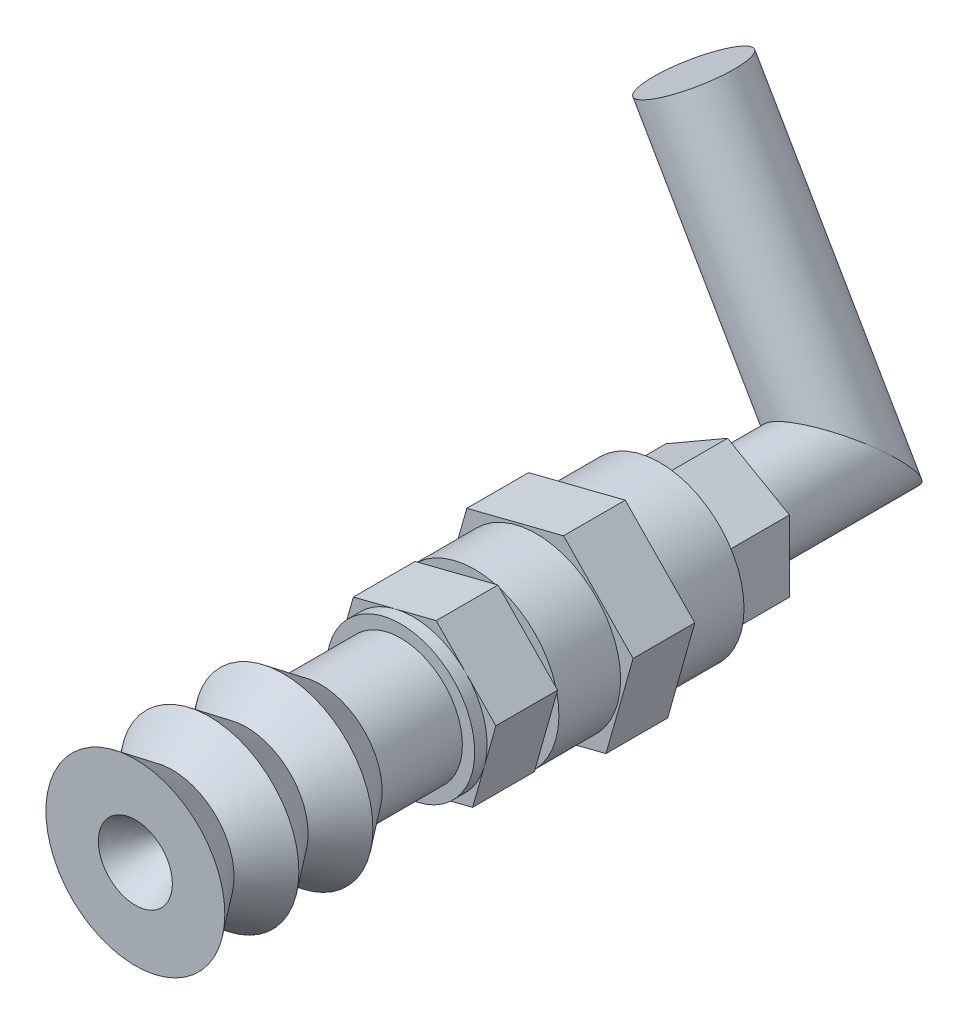
from build123d import *

# Parameters (mm, degrees)
ESQUISSE1_R             = 6.825
BOSS_EXTRU_1_DEPTH      = 5
BOSS_EXTRU_2_DEPTH      = 5
ESQUISSE3_R             = 6.825
BOSS_EXTRU_3_DEPTH      = 5
BOSS_EXTRU_4_DEPTH      = 5
ESQUISSE5_R             = 6
BOSS_EXTRU_5_DEPTH      = 1
ESQUISSE8_R             = 4
BOSS_EXTRU_6_DEPTH      = 4
BOSS_EXTRU_7_DEPTH      = 5.5
ESQUISSE11_R            = 3.75
BOSS_EXTRU_8_DEPTH      = 13
ESQUISSE15_R            = 3.75
BOSS_EXTRU_9_DEPTH      = 19
BOSS_EXTRU_9_DEPTH_BACK = 11
ENL_V_MAT_EXTRU_1_DEPTH = 36
ENL_V_MAT_EXTRU_2_DEPTH = 24


with BuildPart() as part:
    # Esquisse1 → Boss.-Extru.1 (new body)
    with BuildSketch(Plane.XY):
        Circle(ESQUISSE1_R)
    extrude(amount=BOSS_EXTRU_1_DEPTH)

    # Esquisse2 → Boss.-Extru.2 (add)
    with BuildSketch(Plane.XY.offset(5)):
        Polygon((2.197146908, 7.778552487), (-5.637850605, 5.792061282), (-7.834997513, -1.986491205), (-2.197146908, -7.778552487), (5.637850605, -5.792061282), (7.834997513, 1.986491205), align=None)
    extrude(amount=BOSS_EXTRU_2_DEPTH)

    # Esquisse3 → Boss.-Extru.3 (add)
    with BuildSketch(Plane.XY.offset(10)):
        Circle(ESQUISSE3_R)
    extrude(amount=BOSS_EXTRU_3_DEPTH)

    # Esquisse4 → Boss.-Extru.4 (add)
    with BuildSketch(Plane.XY.offset(15)):
        Polygon((1.883268778, 6.667330703), (-4.832443375, 4.964623956), (-6.715712154, -1.702706748), (-1.883268778, -6.667330703), (4.832443375, -4.964623956), (6.715712154, 1.702706748), align=None)
    extrude(amount=BOSS_EXTRU_4_DEPTH)

    # Esquisse5 → Boss.-Extru.5 (add)
    with BuildSketch(Plane.XY.offset(20)):
        with Locations(Location((0, 0, 0), (0, 0, 164.227020734))):
            Circle(ESQUISSE5_R)
    extrude(amount=BOSS_EXTRU_5_DEPTH)

    # Esquisse6 → Révolution1 (revolve)
    with BuildSketch(Plane(origin=(0, 0, 0), x_dir=(0, 0, 1), z_dir=(-0.9623462940986051, 0.2718264340248778, 0)), mode=Mode.PRIVATE) as r_volution1_sk:
        with BuildLine():
            Line((42.5, 7.25), (42.5, 3))
            ThreePointArc((42.5, 3), (40.166189866, 1.626079668), (38.000504816, 0))
            Line((38.000504816, 0), (20, 0))
            Line((20, 0), (20, 5))
            Line((20, 5), (27.5, 5))
            Line((27.5, 5), (30.5, 7.25))
            Line((30.5, 7.25), (33.5, 5))
            Line((33.5, 5), (36.5, 7.25))
            Line((36.5, 7.25), (39.5, 5))
            Line((39.5, 5), (42.5, 7.25))
        make_face()
    revolve(r_volution1_sk.sketch.rotate(Axis((0, 0, 27.429189789), (0, 0, -1)), 74.227020734), axis=Axis((0, 0, 27.429189789), (0, 0, -1)))

    # Esquisse8 → Boss.-Extru.6 (add)
    with BuildSketch(Plane(origin=(0, 0, 20), x_dir=(-1, 0, 0), z_dir=(0, 0, -1))):
        Circle(ESQUISSE8_R)
    extrude(amount=-BOSS_EXTRU_6_DEPTH)

    # Esquisse10 → Boss.-Extru.7 (add)
    with BuildSketch(Plane(origin=(0, 0, 0), x_dir=(-1, 0, 0), z_dir=(0, 0, -1))):
        Polygon((5, -2.886751346), (5, 2.886751346), (0, 5.773502692), (-5, 2.886751346), (-5, -2.886751346), (0, -5.773502692), align=None)
    extrude(amount=BOSS_EXTRU_7_DEPTH)

    # Esquisse11 → Boss.-Extru.8 (add)
    with BuildSketch(Plane(origin=(0, 0, -5.5), x_dir=(-1, 0, 0), z_dir=(0, 0, -1))):
        with Locations(Location((0, 0, 0), (0, 0, 180))):
            Circle(ESQUISSE11_R)
    extrude(amount=BOSS_EXTRU_8_DEPTH)

    # Esquisse15 → Boss.-Extru.9 (add, two sides)
    with BuildSketch(Plane(origin=(-2.5, 4.330127019, 0), x_dir=(0.8660254037844387, 0.4999999999999999, 0), z_dir=(-0.49999999999999994, 0.8660254037844388, 0))) as boss_extru_9_sk:
        with Locations(Location((0, 14.75, 0), (0, 0, 180))):
            Circle(ESQUISSE15_R)
    extrude(amount=BOSS_EXTRU_9_DEPTH)
    extrude(boss_extru_9_sk.sketch, amount=-BOSS_EXTRU_9_DEPTH_BACK)

    # Esquisse17 → Enlèv. mat.-Extru.1 (cut)
    with BuildSketch(Plane(origin=(-12, 20.784609691, 0), x_dir=(0.8660254037844386, 0.5, 0), z_dir=(-0.5000000000000001, 0.8660254037844387, 0))):
        with BuildLine():
            Line((3.75, 14.75), (7.089373521, 14.75))
            Line((7.089373521, 14.75), (7.089373521, 20.468856948))
            Line((7.089373521, 20.468856948), (-7.00273048, 20.468856948))
            Line((-7.00273048, 20.468856948), (-7.00273048, 14.75))
            Line((-7.00273048, 14.75), (-3.75, 14.75))
            ThreePointArc((-3.75, 14.75), (0, 18.5), (3.75, 14.75))
        make_face()
    extrude(amount=-ENL_V_MAT_EXTRU_1_DEPTH, mode=Mode.SUBTRACT)

    # Esquisse18 → Enlèv. mat.-Extru.2 (cut)
    with BuildSketch(Plane(origin=(0, 0, -5.5), x_dir=(-1, 0, 0), z_dir=(0, 0, -1))):
        with BuildLine():
            Line((14.892554705, -8.598220468), (3.247595264, -1.875))
            ThreePointArc((3.247595264, -1.875), (-1.875, -3.247595264), (-3.247595264, 1.875))
            Line((-3.247595264, 1.875), (-12.633967987, 7.294224818))
            Line((-12.633967987, 7.294224818), (-3.446061764, -21.412882035))
            Line((-3.446061764, -21.412882035), (14.892554705, -8.598220468))
        make_face()
    extrude(amount=ENL_V_MAT_EXTRU_2_DEPTH, mode=Mode.SUBTRACT)


solid = part.part
